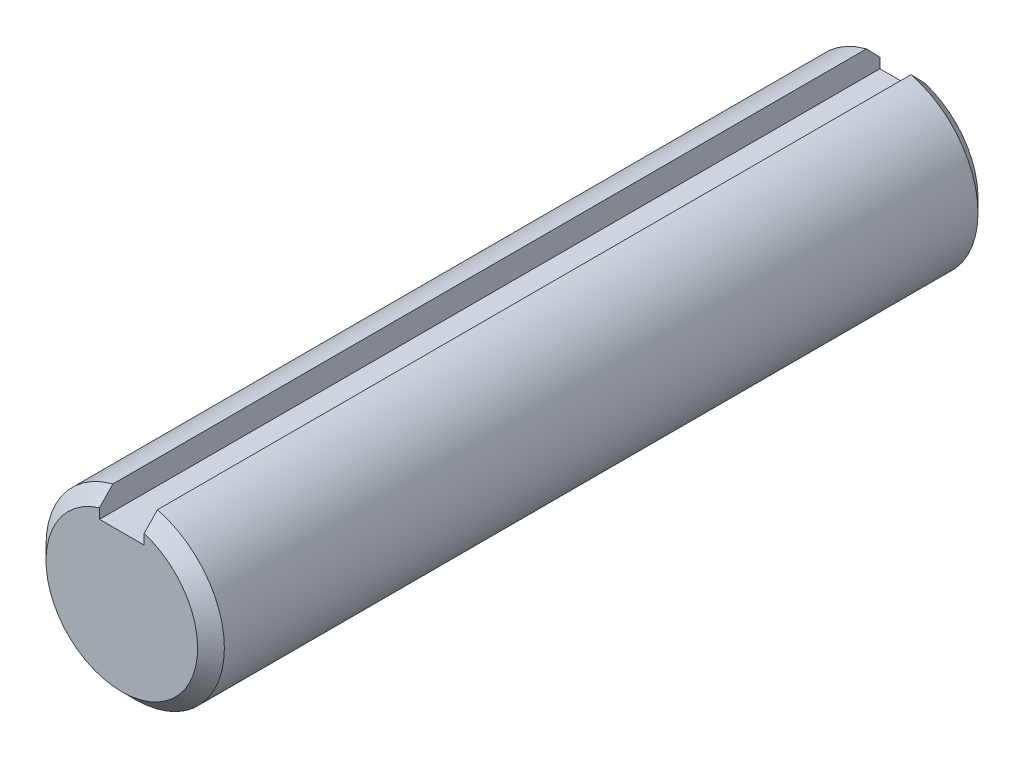
from build123d import *

# Parameters (mm, degrees)
SKETCH1_R           = 4
EXTRUDE1_DEPTH      = 17.5
CHAMFER1_SIZE       = 0.6
SKETCH3_W           = 2
SKETCH3_H           = 1.2
EXTRUDE2_DEPTH      = 18.5
EXTRUDE2_DEPTH_BACK = 18.5


with BuildPart() as part:
    # Sketch1 → Extrude1 (new body, symmetric)
    with BuildSketch(Plane.XY):
        Circle(SKETCH1_R)
    extrude(amount=EXTRUDE1_DEPTH, both=True)

    # Chamfer1
    chamfer1_edges = [part.edges().sort_by_distance(p)[0] for p in [
        (-4, 0, -17.5),
        (-4, 0, 17.5),
    ]]
    chamfer(chamfer1_edges, length=CHAMFER1_SIZE)

    # Sketch3 → Extrude2 (cut, two sides)
    with BuildSketch(Plane.XY) as extrude2_sk:
        with Locations((0, 3.4)):
            Rectangle(SKETCH3_W, SKETCH3_H)
    extrude(amount=EXTRUDE2_DEPTH, mode=Mode.SUBTRACT)
    extrude(extrude2_sk.sketch, amount=-EXTRUDE2_DEPTH_BACK, mode=Mode.SUBTRACT)


solid = part.part
